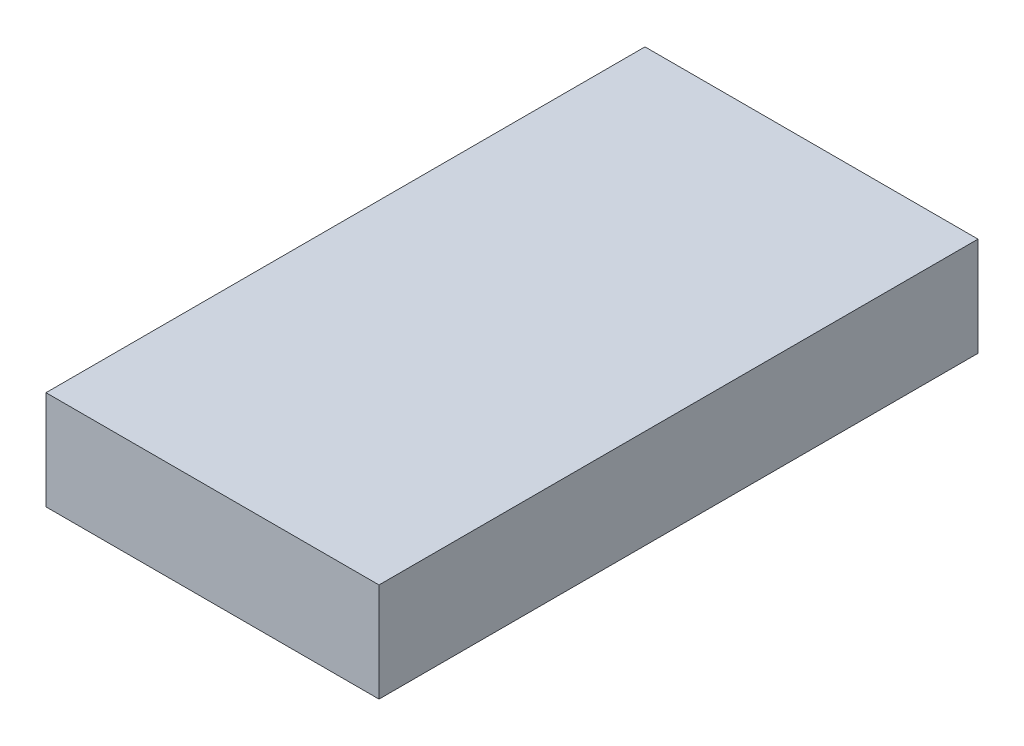
from build123d import *

# Parameters (mm, degrees)
SKETCH1_W           = 26
SKETCH1_H           = 46
BOSS_EXTRUDE1_DEPTH = 5.8
CUT_EXTRUDE1_START  = -0.4
SKETCH2_W           = 24.7
SKETCH2_H           = 45
CUT_EXTRUDE1_DEPTH  = 5
SKETCH3_W           = 30.3
SKETCH3_H           = 54.5
BOSS_EXTRUDE2_DEPTH = 1
SKETCH4_W           = 1
SKETCH4_H           = 54.5
BOSS_EXTRUDE3_DEPTH = 8
SKETCH5_W           = 29.3
SKETCH5_H           = 1
BOSS_EXTRUDE4_DEPTH = 8
SKETCH6_W           = 1
SKETCH6_H           = 53.5
BOSS_EXTRUDE5_DEPTH = 8
SKETCH7_W           = 28.3
SKETCH7_H           = 1
BOSS_EXTRUDE6_DEPTH = 8
SKETCH8_W           = 19.840922592
SKETCH8_H           = 47.393191015
CUT_EXTRUDE2_DEPTH  = 2
SKETCH9_W           = 24.7
SKETCH9_H           = 25.217114116
CUT_EXTRUDE3_DEPTH  = 1


with BuildPart() as part:
    # Sketch1 → Boss-Extrude1 (new body)
    with BuildSketch(Plane(origin=(0, 0, 0), x_dir=(1, 0, 0), z_dir=(0, 1, 0))):
        with Locations((13, 23)):
            Rectangle(SKETCH1_W, SKETCH1_H)
    extrude(amount=BOSS_EXTRUDE1_DEPTH)

    # Sketch2 → Cut-Extrude1 (cut)
    with BuildSketch(Plane(origin=(0, 5.8, 0), x_dir=(1, 0, 0), z_dir=(0, 1, 0)).offset(CUT_EXTRUDE1_START)):
        with Locations((13, 22)):
            Rectangle(SKETCH2_W, SKETCH2_H)
    extrude(amount=-CUT_EXTRUDE1_DEPTH, mode=Mode.SUBTRACT)

    # Sketch3 → Boss-Extrude2 (add)
    with BuildSketch(Plane(origin=(0, 5.8, 0), x_dir=(1, 0, 0), z_dir=(0, 1, 0))):
        with Locations((12.858896044, 21.143191015)):
            Rectangle(SKETCH3_W, SKETCH3_H)
    extrude(amount=BOSS_EXTRUDE2_DEPTH)

    # Sketch4 → Boss-Extrude3 (add)
    with BuildSketch(Plane.XZ.offset(-5.8)):
        with Locations((-1.791103956, -21.143191015)):
            Rectangle(SKETCH4_W, SKETCH4_H)
    extrude(amount=BOSS_EXTRUDE3_DEPTH)

    # Sketch5 → Boss-Extrude4 (add)
    with BuildSketch(Plane.XZ.offset(-5.8)):
        with Locations((13.358896044, 5.606808985)):
            Rectangle(SKETCH5_W, SKETCH5_H)
    extrude(amount=BOSS_EXTRUDE4_DEPTH)

    # Sketch6 → Boss-Extrude5 (add)
    with BuildSketch(Plane.XZ.offset(-5.8)):
        with Locations((27.508896044, -21.643191015)):
            Rectangle(SKETCH6_W, SKETCH6_H)
    extrude(amount=BOSS_EXTRUDE5_DEPTH)

    # Sketch7 → Boss-Extrude6 (add)
    with BuildSketch(Plane.XZ.offset(-5.8)):
        with Locations((12.858896044, -47.893191015)):
            Rectangle(SKETCH7_W, SKETCH7_H)
    extrude(amount=BOSS_EXTRUDE6_DEPTH)

    # Sketch8 → Cut-Extrude2 (cut)
    with BuildSketch(Plane.XZ):
        with Locations((12.675861703, -23.696595508)):
            Rectangle(SKETCH8_W, SKETCH8_H)
    extrude(amount=-CUT_EXTRUDE2_DEPTH, mode=Mode.SUBTRACT)

    # Sketch9 → Cut-Extrude3 (cut)
    with BuildSketch(Plane.XZ):
        with Locations((13.034968762, -12.580450922)):
            Rectangle(SKETCH9_W, SKETCH9_H)
    extrude(amount=-CUT_EXTRUDE3_DEPTH, mode=Mode.SUBTRACT)


solid = part.part
